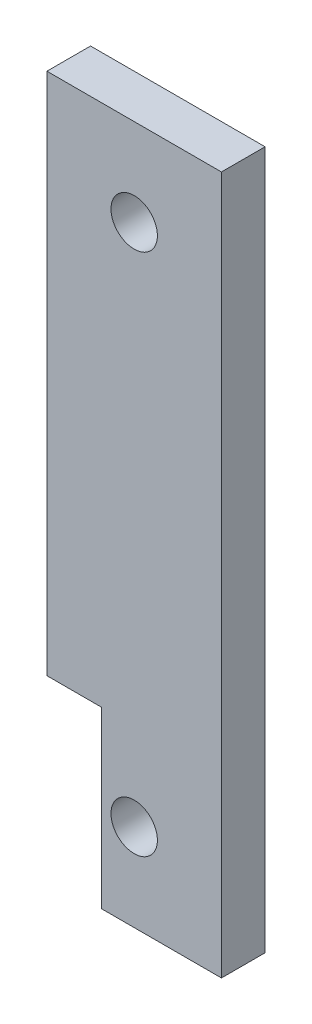
from build123d import *

# Parameters (mm, degrees)
SKETCH1_W                    = 25.4
SKETCH1_H                    = 6.35
BOSS_EXTRUDE1_DEPTH          = 101.6
H_0_266_DIAMETER_HOLE1_D     = 6.7564
H_0_266_DIAMETER_HOLE1_DEPTH = 6.35
SKETCH4_W                    = 7.9375
SKETCH4_H                    = 25.4
CUT_EXTRUDE1_DEPTH           = 7.35


with BuildPart() as part:
    # Sketch1 → Boss-Extrude1 (new body)
    with BuildSketch(Plane(origin=(0, 0, 0), x_dir=(1, 0, 0), z_dir=(0, 1, 0))):
        with Locations((12.7, 3.175)):
            Rectangle(SKETCH1_W, SKETCH1_H)
    extrude(amount=BOSS_EXTRUDE1_DEPTH)

    # H (0.266) Diameter Hole1
    with Locations(Plane.XY):
        with Locations((12.7, 88.9), (12.7, 12.7)):
            Hole(H_0_266_DIAMETER_HOLE1_D / 2, depth=H_0_266_DIAMETER_HOLE1_DEPTH)

    # Sketch4 → Cut-Extrude1 (cut, through all)
    with BuildSketch(Plane(origin=(0, 0, -6.35), x_dir=(-1, 0, 0), z_dir=(0, 0, -1))):
        with Locations((-3.96875, 12.7)):
            Rectangle(SKETCH4_W, SKETCH4_H)
    extrude(amount=-CUT_EXTRUDE1_DEPTH, mode=Mode.SUBTRACT)


solid = part.part
